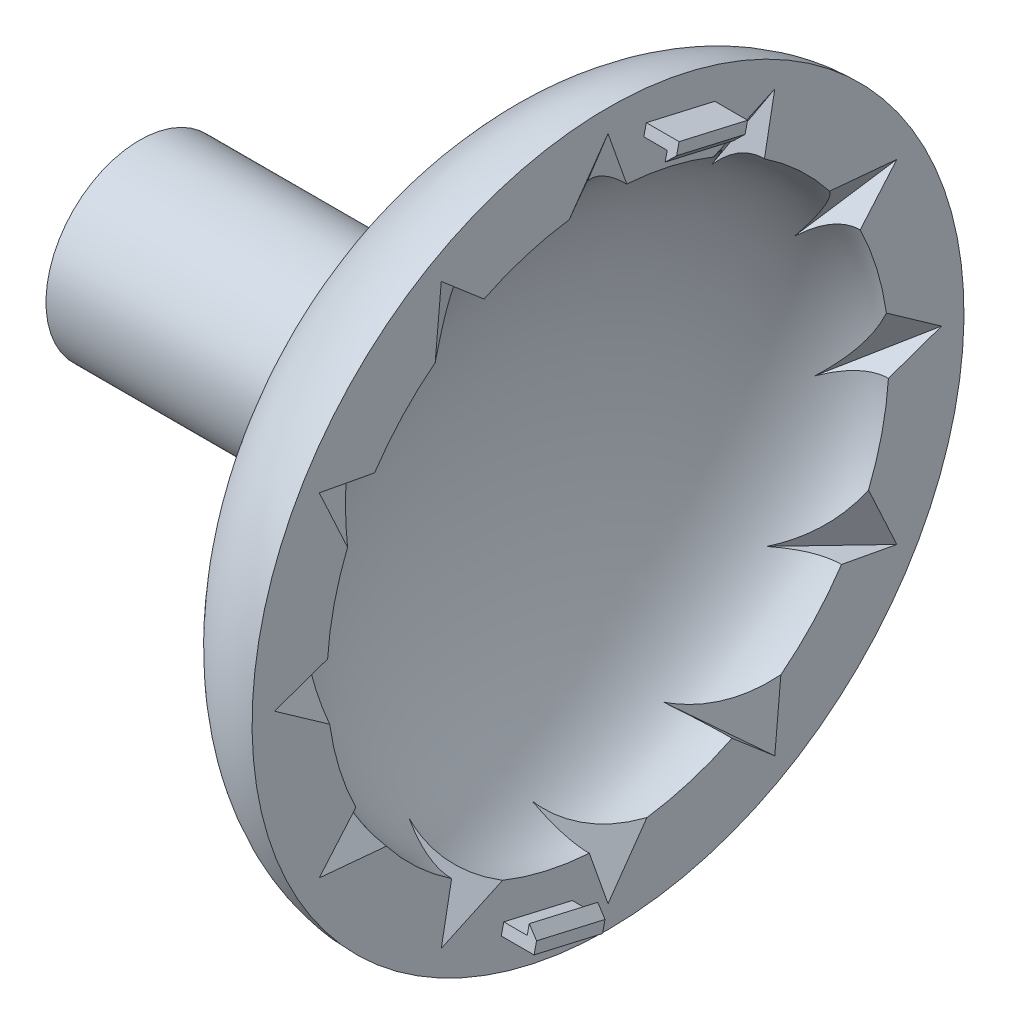
from build123d import *

# Parameters (mm, degrees)
CIRPATTERN1_COUNT   = 12
BOSS_EXTRUDE1_DEPTH = 4.445
BOSS_EXTRUDE2_DEPTH = 9.525
BOSS_EXTRUDE3_REACH = 69.945
SKETCH8_R           = 12.7


with BuildPart() as part:
    # Sketch1 → Revolve2 (revolve)
    with BuildSketch(Plane.XY):
        with BuildLine():
            add(Edge.make_bspline(
                [(0, 48.26), (-26.035, 48.26), (-26.035, 0)],
                knots=[3.141592654, 3.141592654, 3.141592654, 4.71238898, 4.71238898, 4.71238898], degree=2, weights=[1, 0.707106781, 1]))
            Line((-26.035, 0), (-15.875, 0))
            add(Edge.make_bspline(
                [(0, 38.1), (-15.875, 38.1), (-15.875, 0)],
                knots=[3.141592654, 3.141592654, 3.141592654, 4.71238898, 4.71238898, 4.71238898], degree=2, weights=[1, 0.707106781, 1]))
            Line((0, 38.1), (0, 48.26))
        make_face()
    revolve(axis=Axis((-26.035, 0, 0), (1, 0, 0)))

    # Sketch2 → Cut-Loft1 section 0
    with BuildSketch(Plane(origin=(0, -34.29, 0), x_dir=(1, 0, 0), z_dir=(0, 1, 0)), mode=Mode.PRIVATE) as cut_loft1_s0:
        Polygon((0, 7.69896584), (-6.6675, -3.84948292), (6.6675, -3.84948292), align=None)
    cut_loft1 = loft([cut_loft1_s0.sketch, Vertex(0, -45.212, 0)], mode=Mode.SUBTRACT)

    # CirPattern1: Cut-Loft1 ×12 about axis
    cirpattern1_axis = Axis((0, 0, 0), (1, 0, 0))
    for i in range(1, CIRPATTERN1_COUNT):
        add(cut_loft1.rotate(cirpattern1_axis, i * 360 / CIRPATTERN1_COUNT), mode=Mode.SUBTRACT)

    # Sketch6 → Boss-Extrude1 (add)
    with BuildSketch(Plane(origin=(0, 0, 0), x_dir=(0, 0, -1), z_dir=(1, 0, 0))):
        Polygon((4.851243253, 42.407942289), (14.134652823, 40.27629228), (14.475716824, 41.761637811), (5.192307254, 43.89328782), align=None)
    boss_extrude1 = extrude(amount=BOSS_EXTRUDE1_DEPTH)

    # Sketch7 → Boss-Extrude2 (add)
    with BuildSketch(Plane(origin=(0, 1.065825004, 4.641704785), x_dir=(1, 0, 0), z_dir=(0, 0.223795276, 0.974636175))):
        Polygon((3.175, 42.418), (3.175, 41.148), (4.445, 42.418), align=None)
    boss_extrude2 = extrude(amount=-BOSS_EXTRUDE2_DEPTH)

    # Mirror1: Boss-Extrude1, Boss-Extrude2 across plane
    add(boss_extrude1.mirror(Plane(origin=(0, 0, 0), x_dir=(0, 0.223795276, 0.974636175), z_dir=(0, -0.974636175, 0.223795276))))
    add(boss_extrude2.mirror(Plane(origin=(0, 0, 0), x_dir=(0, 0.223795276, 0.974636175), z_dir=(0, -0.974636175, 0.223795276))))

    # Sketch8 → Boss-Extrude3 (add, up to next)
    with BuildSketch(Plane(origin=(-63.5, 0, 0), x_dir=(0, 0, -1), z_dir=(1, 0, 0)), mode=Mode.PRIVATE) as boss_extrude3_sk1:
        Circle(SKETCH8_R)
    boss_extrude3_tool1 = extrude(boss_extrude3_sk1.sketch, amount=BOSS_EXTRUDE3_REACH, mode=Mode.PRIVATE) - part.part
    add(boss_extrude3_tool1.solids().sort_by_distance((-63.5, 0, 0))[0])


solid = part.part
